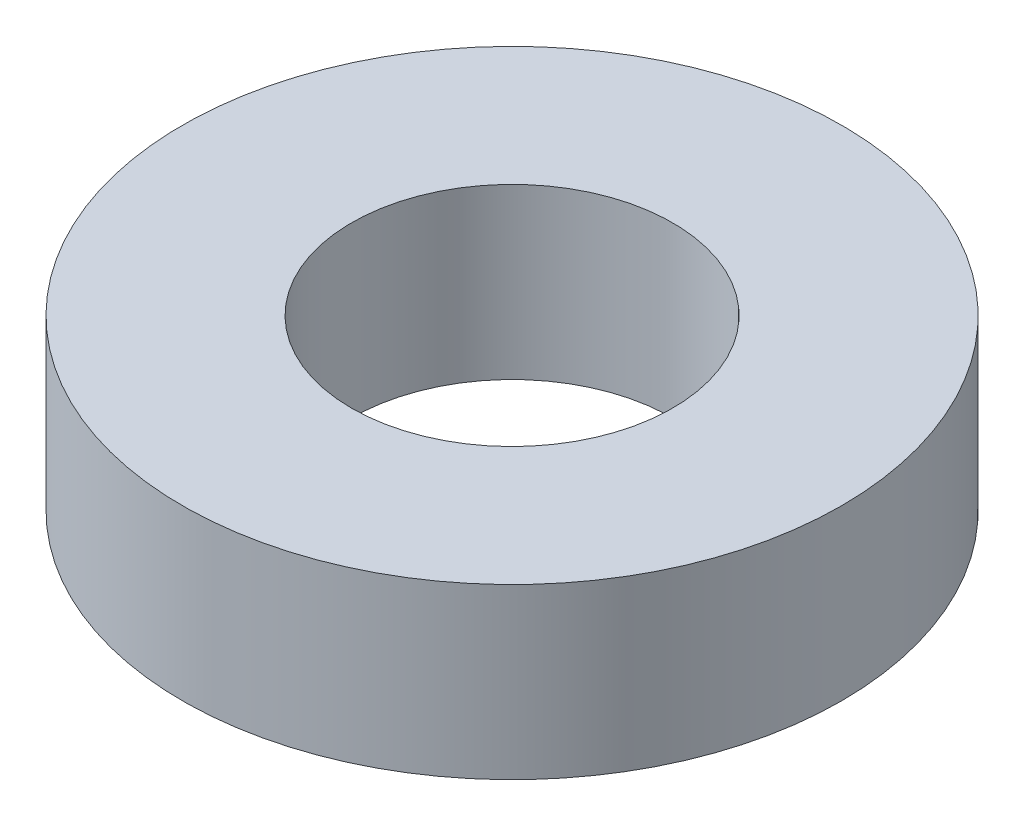
from build123d import *

# Parameters (mm, degrees)
SKETCH_1_R      = 3.9
SKETCH_1_R_2    = 1.9
EXTRUDE_1_DEPTH = 2


with BuildPart() as part:
    # 草图1 → 拉伸-薄壁1 (new body)
    with BuildSketch(Plane(origin=(0, 0, 0), x_dir=(1, 0, 0), z_dir=(0, 1, 0))):
        Circle(SKETCH_1_R)
        Circle(SKETCH_1_R_2, mode=Mode.SUBTRACT)
    extrude(amount=EXTRUDE_1_DEPTH)


solid = part.part
